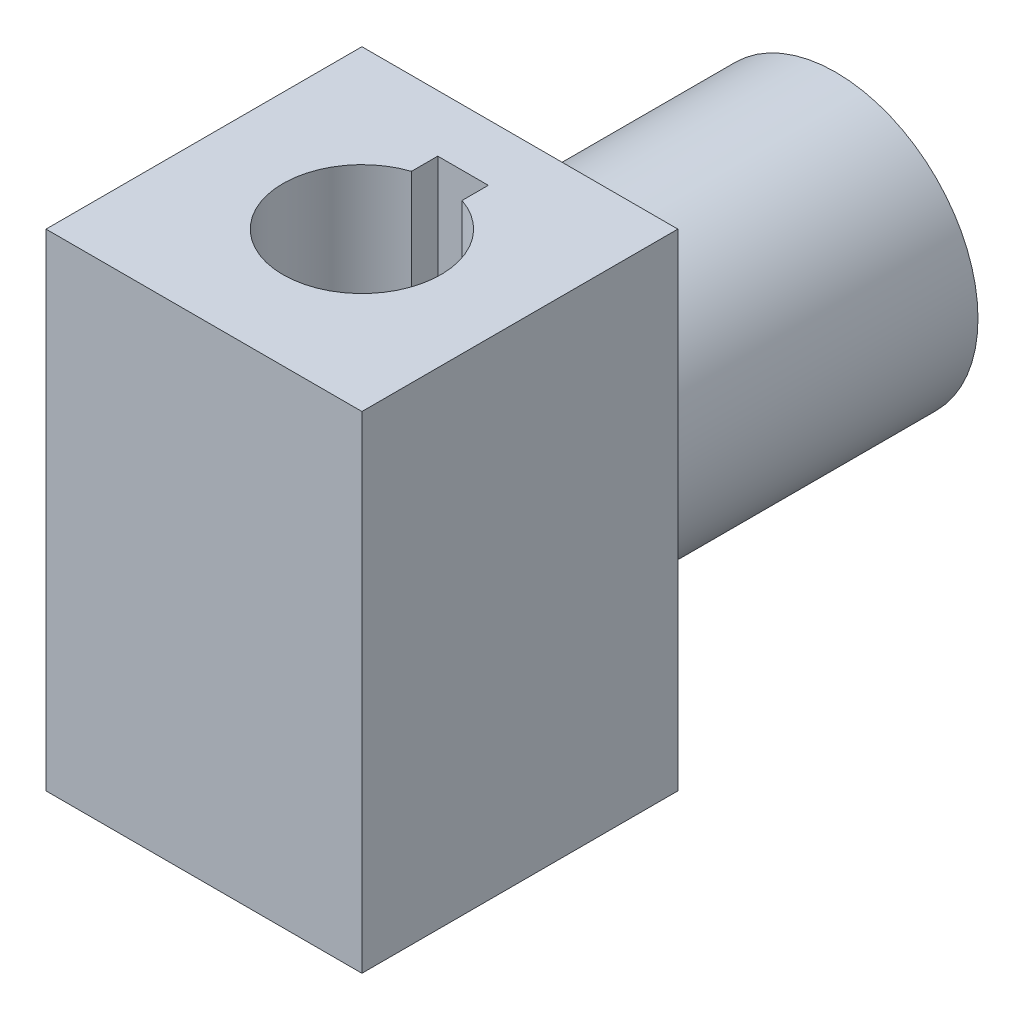
from build123d import *

# Parameters (mm, degrees)
SKETCH1_W           = 50
SKETCH1_H           = 50
BOSS_EXTRUDE1_DEPTH = 77
SKETCH2_R           = 22.5
BOSS_EXTRUDE2_DEPTH = 50


with BuildPart() as part:
    # Sketch1 → Boss-Extrude1 (new body)
    with BuildSketch(Plane(origin=(0, 0, 0), x_dir=(1, 0, 0), z_dir=(0, 1, 0))):
        Rectangle(SKETCH1_W, SKETCH1_H)
        with BuildLine():
            Line((4, 16), (4, 11.842719282))
            ThreePointArc((4, 11.842719282), (10.155048006, 7.288689869), (12.5, 0))
            ThreePointArc((12.5, 0), (-7.288689869, -10.155048006), (-4, 11.842719282))
            Line((-4, 11.842719282), (-4, 16))
            Line((-4, 16), (4, 16))
        make_face(mode=Mode.SUBTRACT)
    extrude(amount=BOSS_EXTRUDE1_DEPTH)

    # Sketch2 → Boss-Extrude2 (add)
    with BuildSketch(Plane(origin=(0, 0, -25), x_dir=(-1, 0, 0), z_dir=(0, 0, -1))):
        with Locations((0, 38.5)):
            Circle(SKETCH2_R)
    extrude(amount=BOSS_EXTRUDE2_DEPTH)


solid = part.part
